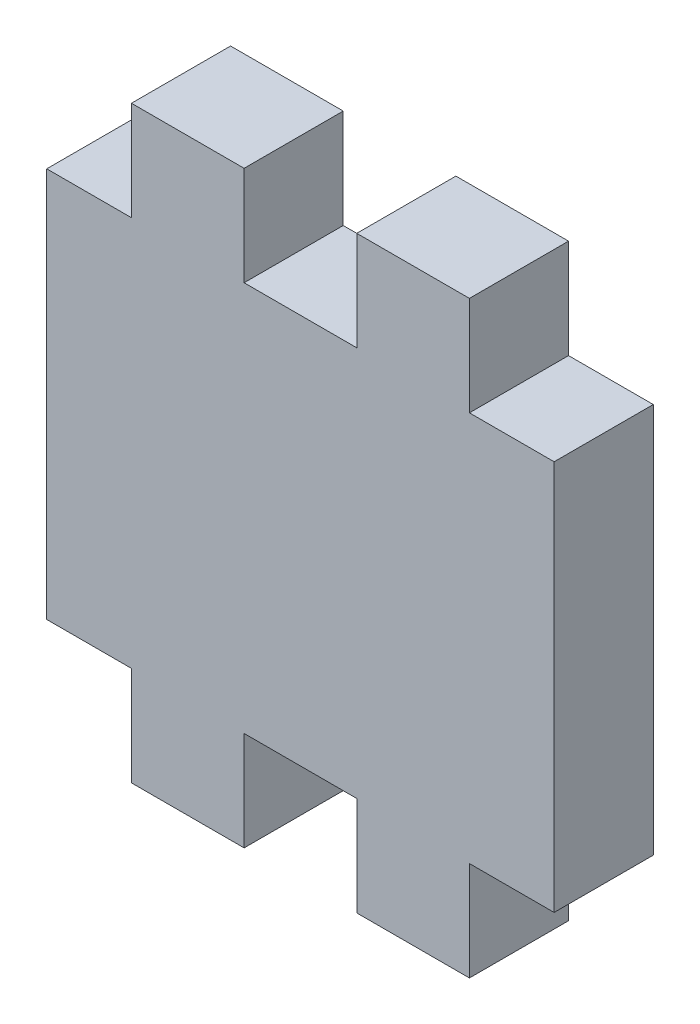
from build123d import *

# Parameters (mm, degrees)
BOSS_EXTRUDE1_DEPTH = 5.588


with BuildPart() as part:
    # Sketch1 → Boss-Extrude1 (new body)
    with BuildSketch(Plane.XY):
        Polygon((0, 0), (4.775, 0), (4.775, -5.588), (11.125, -5.588), (11.125, 0), (17.475, 0), (17.475, -5.588), (23.825, -5.588), (23.825, 0), (28.6, 0), (28.6, 22), (23.825, 22), (23.825, 27.588), (17.475, 27.588), (17.475, 22), (11.125, 22), (11.125, 27.588), (4.775, 27.588), (4.775, 22), (0, 22), align=None)
    extrude(amount=BOSS_EXTRUDE1_DEPTH)


solid = part.part
